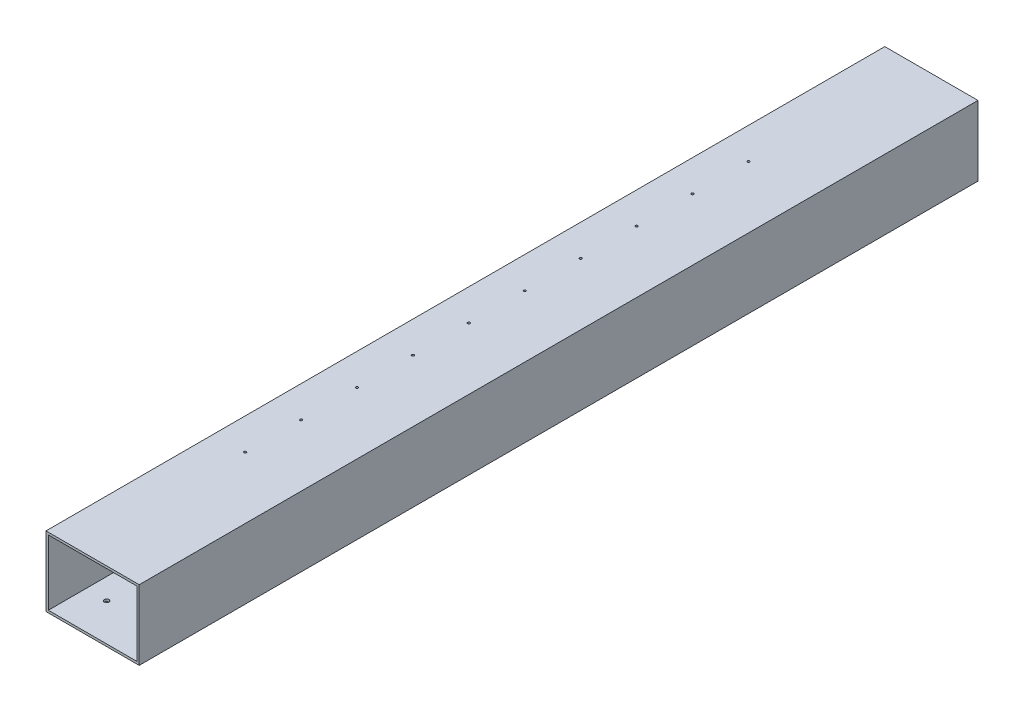
from build123d import *

# Parameters (mm, degrees)
SKETCH2_W           = 200
SKETCH2_H           = 150
SKETCH2_W_2         = 190
SKETCH2_H_2         = 140
BOSS_EXTRUDE1_DEPTH = 1800
SKETCH5_R           = 2.5
CUT_EXTRUDE3_DEPTH  = 10
SKETCH6_R           = 5
SKETCH6_R_2         = 2
CUT_EXTRUDE4_DEPTH  = 5


with BuildPart() as part:
    # Sketch2 → Boss-Extrude1 (new body)
    with BuildSketch(Plane.XY):
        Rectangle(SKETCH2_W, SKETCH2_H)
        Rectangle(SKETCH2_W_2, SKETCH2_H_2, mode=Mode.SUBTRACT)
    extrude(amount=BOSS_EXTRUDE1_DEPTH)

    # Sketch5 → Cut-Extrude3 (cut)
    with BuildSketch(Plane(origin=(0, 75, 0), x_dir=(1, 0, 0), z_dir=(0, 1, 0))):
        with Locations((-32.7, -360)):
            Circle(SKETCH5_R)
        with Locations((-32.7, -480)):
            Circle(SKETCH5_R)
        with Locations((-32.7, -600)):
            Circle(SKETCH5_R)
        with Locations((-32.7, -720)):
            Circle(SKETCH5_R)
        with Locations((-32.7, -840)):
            Circle(SKETCH5_R)
        with Locations((-32.7, -960)):
            Circle(SKETCH5_R)
        with Locations((-32.7, -1080)):
            Circle(SKETCH5_R)
        with Locations((-32.7, -1200)):
            Circle(SKETCH5_R)
        with Locations((-32.7, -1320)):
            Circle(SKETCH5_R)
        with Locations((-32.7, -1440)):
            Circle(SKETCH5_R)
    extrude(amount=-CUT_EXTRUDE3_DEPTH, mode=Mode.SUBTRACT)

    # Sketch6 → Cut-Extrude4 (cut)
    with BuildSketch(Plane.XZ.offset(75)):
        with Locations((-50, 1720)):
            Circle(SKETCH6_R)
        with Locations((50, 1720)):
            Circle(SKETCH6_R)
        with Locations((50, 1590)):
            Circle(SKETCH6_R)
        with Locations((-50, 1590)):
            Circle(SKETCH6_R)
        with Locations((50, 1412.5)):
            Circle(SKETCH6_R_2)
        with Locations((50, 1387.5)):
            Circle(SKETCH6_R_2)
        with Locations((50, 1162.5)):
            Circle(SKETCH6_R_2)
        with Locations((50, 1137.5)):
            Circle(SKETCH6_R_2)
        with Locations((50, 912.5)):
            Circle(SKETCH6_R_2)
        with Locations((50, 887.5)):
            Circle(SKETCH6_R_2)
        with Locations((50, 662.5)):
            Circle(SKETCH6_R_2)
        with Locations((50, 637.5)):
            Circle(SKETCH6_R_2)
        with Locations((50, 412.5)):
            Circle(SKETCH6_R_2)
        with Locations((50, 387.5)):
            Circle(SKETCH6_R_2)
        with Locations((-50, 210)):
            Circle(SKETCH6_R)
        with Locations((50, 210)):
            Circle(SKETCH6_R)
        with Locations((50, 80)):
            Circle(SKETCH6_R)
        with Locations((-50, 80)):
            Circle(SKETCH6_R)
    extrude(amount=-CUT_EXTRUDE4_DEPTH, mode=Mode.SUBTRACT)


solid = part.part
